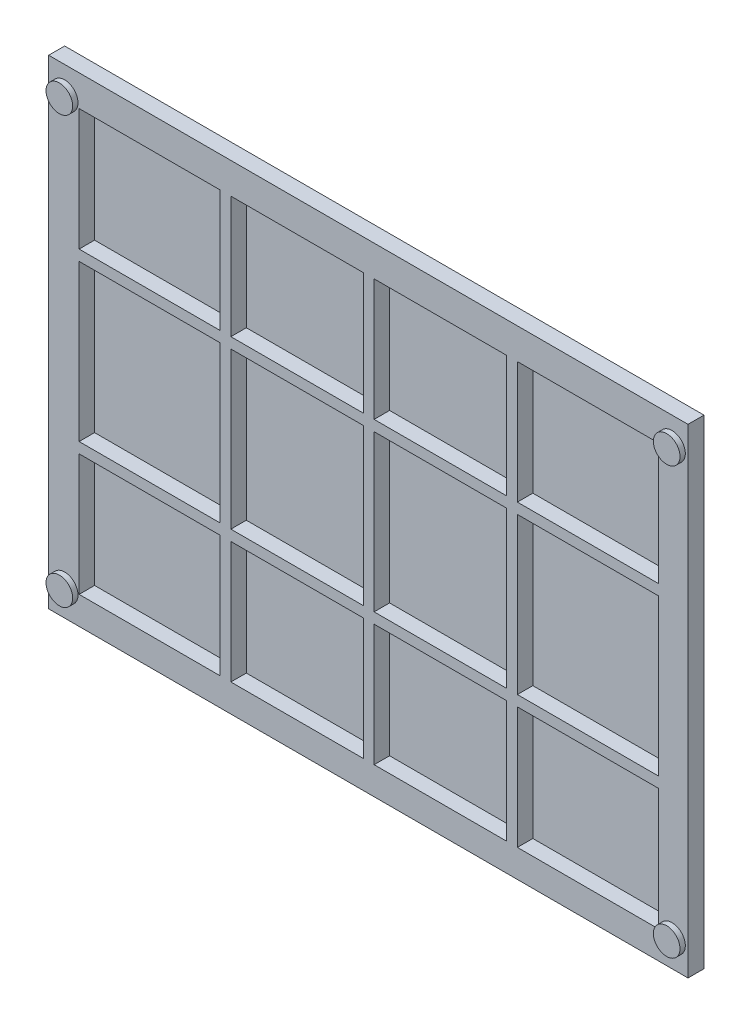
from build123d import *

# Parameters (mm, degrees)
SKETCH2_W           = 1200
SKETCH2_H           = 900
BOSS_EXTRUDE2_DEPTH = 30
SKETCH3_W           = 1087.423470631
SKETCH3_H           = 789.777232946
CUT_EXTRUDE2_DEPTH  = 29
RIB6_REACH          = 1502.3
SKETCH6_WALLS_W     = 20
SKETCH6_WALLS_H     = 3792.377172958
SKETCH6_WALLS_W_2   = 4090.023410643
SKETCH6_WALLS_H_2   = 20
SKETCH7_R           = 25
BOSS_EXTRUDE3_DEPTH = 10


with BuildPart() as part:
    # Sketch2 → Boss-Extrude2 (new body)
    with BuildSketch(Plane.XY):
        with Locations((600, 450)):
            Rectangle(SKETCH2_W, SKETCH2_H)
    extrude(amount=BOSS_EXTRUDE2_DEPTH)

    # Sketch3 → Cut-Extrude2 (cut)
    with BuildSketch(Plane.XY.offset(30)):
        with Locations((600.845585903, 447.040449341)):
            Rectangle(SKETCH3_W, SKETCH3_H)
    extrude(amount=-CUT_EXTRUDE2_DEPTH, mode=Mode.SUBTRACT)

    # Sketch6 walls → Rib6 (add, up to next)
    with BuildSketch(Plane.XY.offset(30), mode=Mode.PRIVATE) as rib6_sk1:
        with Locations((600.845585903, 447.040449341)):
            Rectangle(SKETCH6_WALLS_W, SKETCH6_WALLS_H)
    rib6_tool1 = extrude(rib6_sk1.sketch, amount=-RIB6_REACH, mode=Mode.PRIVATE) - part.part
    # Sketch6 walls → Rib6 (add, up to next)
    with BuildSketch(Plane.XY.offset(30), mode=Mode.PRIVATE) as rib6_sk2:
        with Locations((331.949268904, 447.040449341)):
            Rectangle(SKETCH6_WALLS_W, SKETCH6_WALLS_H)
    rib6_tool2 = extrude(rib6_sk2.sketch, amount=-RIB6_REACH, mode=Mode.PRIVATE) - part.part
    # Sketch6 walls → Rib6 (add, up to next)
    with BuildSketch(Plane.XY.offset(30), mode=Mode.PRIVATE) as rib6_sk3:
        with Locations((600.845585903, 603.473841306)):
            Rectangle(SKETCH6_WALLS_W_2, SKETCH6_WALLS_H_2)
    rib6_tool3 = extrude(rib6_sk3.sketch, amount=-RIB6_REACH, mode=Mode.PRIVATE) - part.part
    # Sketch6 walls → Rib6 (add, up to next)
    with BuildSketch(Plane.XY.offset(30), mode=Mode.PRIVATE) as rib6_sk4:
        with Locations((869.741902901, 447.040449341)):
            Rectangle(SKETCH6_WALLS_W, SKETCH6_WALLS_H)
    rib6_tool4 = extrude(rib6_sk4.sketch, amount=-RIB6_REACH, mode=Mode.PRIVATE) - part.part
    # Sketch6 walls → Rib6 (add, up to next)
    with BuildSketch(Plane.XY.offset(30), mode=Mode.PRIVATE) as rib6_sk5:
        with Locations((600.845585903, 290.607057376)):
            Rectangle(SKETCH6_WALLS_W_2, SKETCH6_WALLS_H_2)
    rib6_tool5 = extrude(rib6_sk5.sketch, amount=-RIB6_REACH, mode=Mode.PRIVATE) - part.part
    add(rib6_tool1.solids().sort_by_distance((600.845585903, 447.040449341, 30))[0])
    add(rib6_tool2.solids().sort_by_distance((331.949268904, 447.040449341, 30))[0])
    add(rib6_tool3.solids().sort_by_distance((600.845585903, 603.473841306, 30))[0])
    add(rib6_tool4.solids().sort_by_distance((869.741902901, 447.040449341, 30))[0])
    add(rib6_tool5.solids().sort_by_distance((600.845585903, 290.607057376, 30))[0])

    # Sketch7 → Boss-Extrude3 (add)
    with BuildSketch(Plane.XY.offset(30)):
        with Locations(Location((30, 850, 0), (0, 0, 180))):
            Circle(SKETCH7_R)
        with Locations(Location((30, 50, 0), (0, 0, 180))):
            Circle(SKETCH7_R)
        with Locations(Location((1170, 50, 0), (0, 0, 180))):
            Circle(SKETCH7_R)
        with Locations(Location((1170, 850, 0), (0, 0, 180))):
            Circle(SKETCH7_R)
    extrude(amount=BOSS_EXTRUDE3_DEPTH)


solid = part.part
